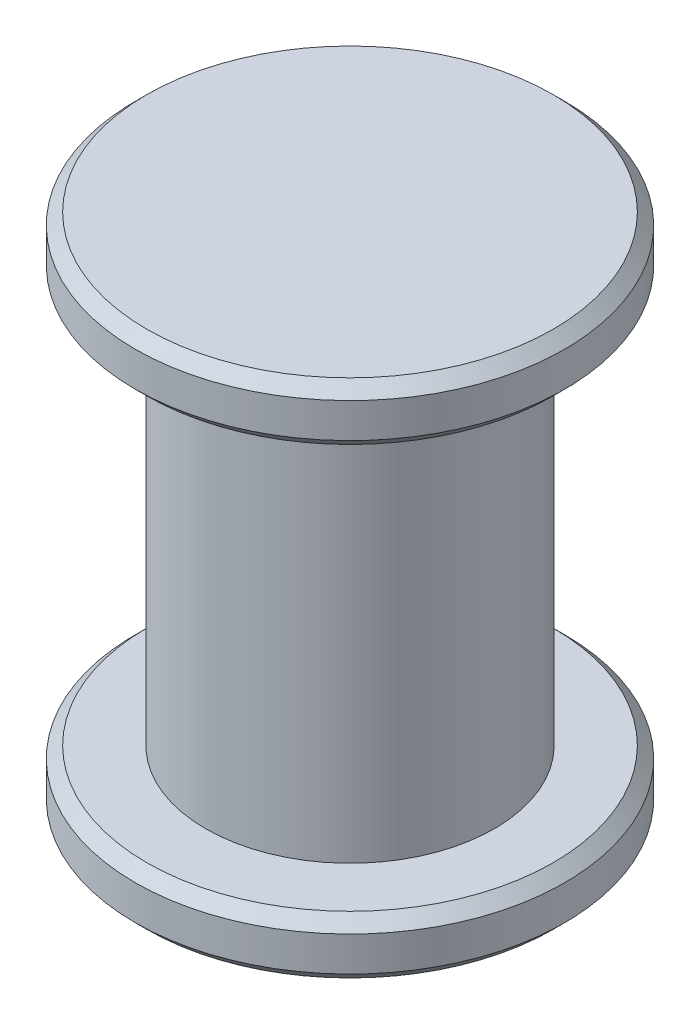
from build123d import *

# Parameters (mm, degrees)
SKETCH2_R           = 0.25
BOSS_EXTRUDE1_DEPTH = 0.7
SKETCH3_R           = 0.371871199
BOSS_EXTRUDE2_DEPTH = 0.1
SKETCH4_R           = 0.371871199
BOSS_EXTRUDE3_DEPTH = 0.1
CHAMFER1_SIZE       = 0.02
CHAMFER2_SIZE       = 0.02
CHAMFER3_SIZE       = 0.02


with BuildPart() as part:
    # Sketch2 → Boss-Extrude1 (new body)
    with BuildSketch(Plane(origin=(0, 0, 0), x_dir=(1, 0, 0), z_dir=(0, 1, 0))):
        Circle(SKETCH2_R)
    extrude(amount=BOSS_EXTRUDE1_DEPTH)

    # Sketch3 → Boss-Extrude2 (add)
    with BuildSketch(Plane(origin=(0, 0.7, 0), x_dir=(1, 0, 0), z_dir=(0, 1, 0))):
        Circle(SKETCH3_R)
    extrude(amount=BOSS_EXTRUDE2_DEPTH)

    # Sketch4 → Boss-Extrude3 (add)
    with BuildSketch(Plane.XZ):
        Circle(SKETCH4_R)
    extrude(amount=BOSS_EXTRUDE3_DEPTH)

    # Chamfer1
    chamfer1_edges = [part.edges().sort_by_distance(p)[0] for p in [
        (-0.371871199, 0.8, 0),
    ]]
    chamfer(chamfer1_edges, length=CHAMFER1_SIZE)

    # Chamfer2
    chamfer2_edges = [part.edges().sort_by_distance(p)[0] for p in [
        (-0.371871199, 0.7, 0),
        (-0.371871199, 0, 0),
    ]]
    chamfer(chamfer2_edges, length=CHAMFER2_SIZE)

    # Chamfer3
    chamfer3_edges = [part.edges().sort_by_distance(p)[0] for p in [
        (-0.371871199, -0.1, 0),
    ]]
    chamfer(chamfer3_edges, length=CHAMFER3_SIZE)


solid = part.part
